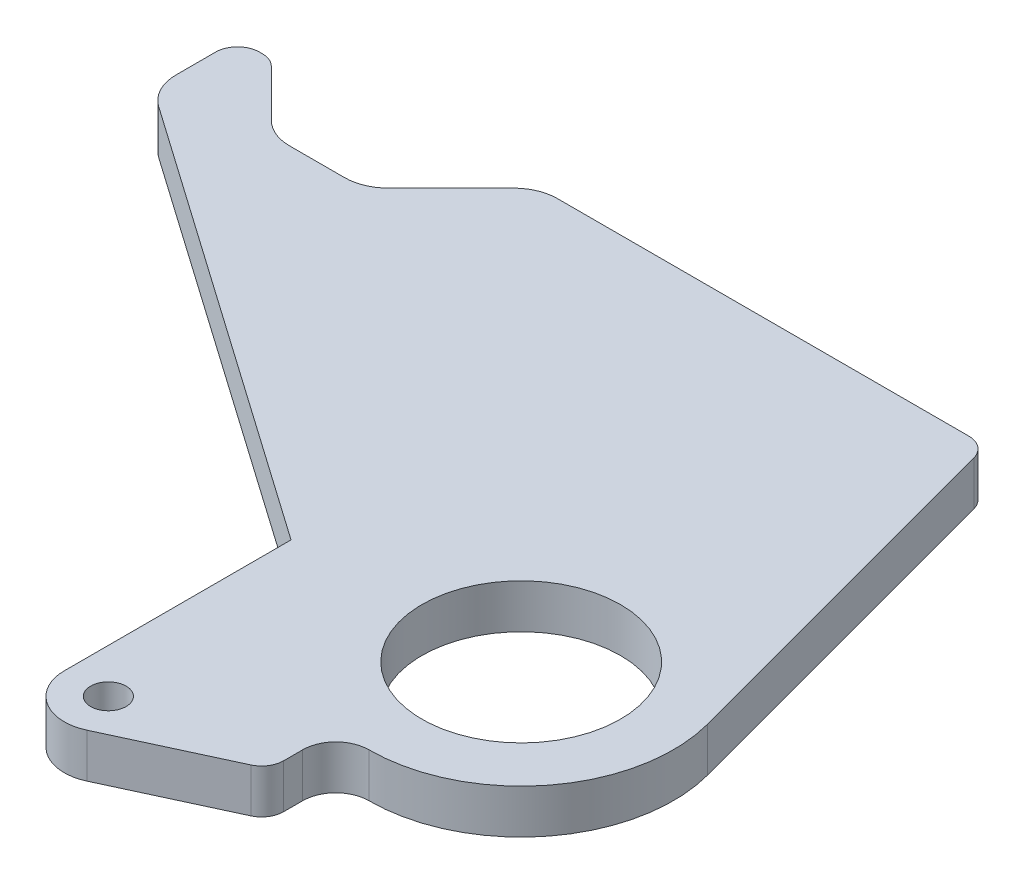
from build123d import *

# Parameters (mm, degrees)
SKETCH1_R           = 2.5527
SKETCH1_R_2         = 14.2875
BOSS_EXTRUDE1_DEPTH = 6.35


with BuildPart() as part:
    # Sketch1 → Boss-Extrude1 (new body)
    with BuildSketch(Plane(origin=(0, 0, 0), x_dir=(1, 0, 0), z_dir=(0, 1, 0))):
        with BuildLine():
            Line((4.080014702, 60.325), (-55.087853576, 60.325))
            ThreePointArc((-55.087853576, 60.325), (-57.517893372, 59.841635031), (-59.577981637, 58.465128061))
            Line((-59.577981637, 58.465128061), (-68.558237758, 49.484871939))
            ThreePointArc((-68.558237758, 49.484871939), (-70.618326023, 48.108364969), (-73.048365818, 47.625))
            Line((-73.048365818, 47.625), (-80.939134182, 47.625))
            ThreePointArc((-80.939134182, 47.625), (-83.369173977, 48.108364969), (-85.429262242, 49.484871939))
            Line((-85.429262242, 49.484871939), (-92.164454333, 56.22006403))
            ThreePointArc((-92.164454333, 56.22006403), (-93.194498465, 56.908317516), (-94.409518363, 57.15))
            Line((-94.409518363, 57.15), (-94.77375, 57.15))
            ThreePointArc((-94.77375, 57.15), (-97.01881403, 56.22006403), (-97.94875, 53.975))
            Line((-97.94875, 53.975), (-97.94875, 48.299136826))
            ThreePointArc((-97.94875, 48.299136826), (-97.231268791, 45.367033132), (-95.240960371, 43.097521344))
            Line((-95.240960371, 43.097521344), (-31.75, -1.359327715))
            Line((-31.75, -1.359327715), (-31.75, -33.9852))
            ThreePointArc((-31.75, -33.9852), (-28.819730055, -39.335708981), (-22.733323984, -39.748127991))
            Line((-22.733323984, -39.748127991), (-6.604161992, -32.284691086))
            ThreePointArc((-6.604161992, -32.284691086), (-5.26224551, -31.113092118), (-4.7625, -29.403227091))
            Line((-4.7625, -29.403227091), (-4.7625, -26.67))
            ThreePointArc((-4.7625, -26.67), (-3.367596045, -23.302403955), (0, -21.9075))
            ThreePointArc((0, -21.9075), (17.380388302, -13.336441006), (21.161020039, 5.670078231))
            Line((21.161020039, 5.670078231), (7.146829201, 57.971750468))
            ThreePointArc((7.146829201, 57.971750468), (6.012832239, 59.668896855), (4.080014702, 60.325))
        make_face()
        with Locations((-25.4, -33.9852)):
            Circle(SKETCH1_R, mode=Mode.SUBTRACT)
        Circle(SKETCH1_R_2, mode=Mode.SUBTRACT)
    extrude(amount=-BOSS_EXTRUDE1_DEPTH)


solid = part.part
